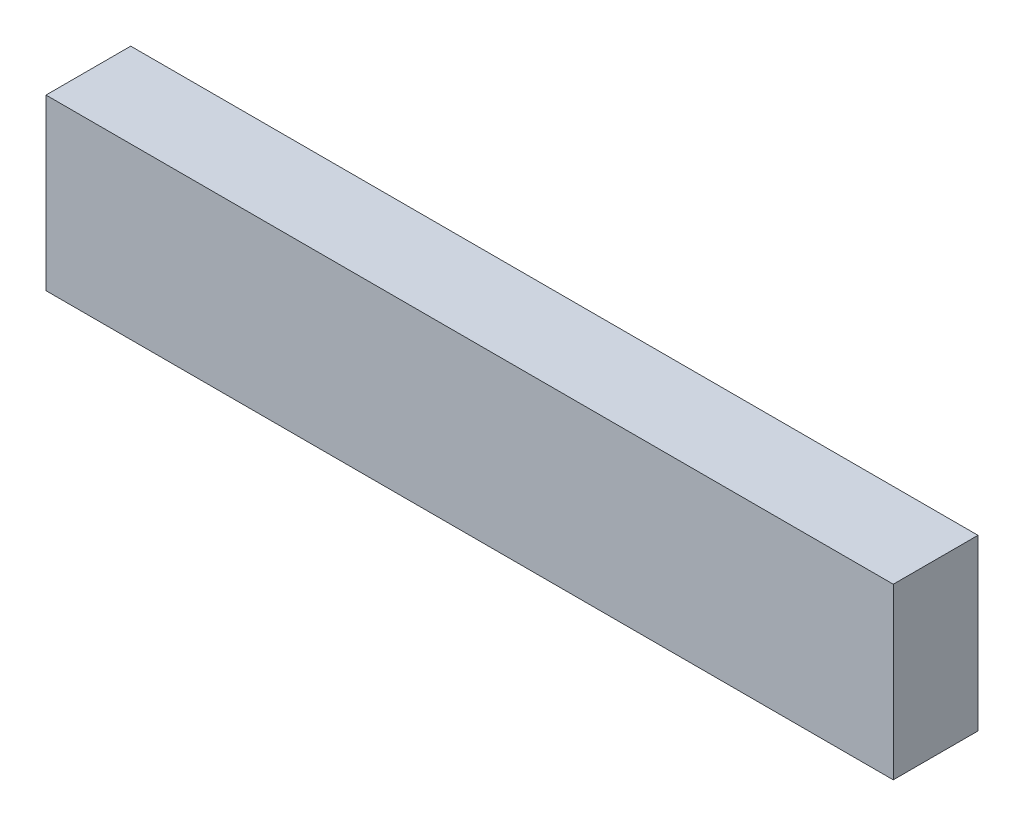
from build123d import *

# Parameters (mm, degrees)
SKETCH2_W           = 50
SKETCH2_H           = 10
BOSS_EXTRUDE1_DEPTH = 5


with BuildPart() as part:
    # Sketch2 → Boss-Extrude1 (new body)
    with BuildSketch(Plane.XY):
        with Locations((25, -5)):
            Rectangle(SKETCH2_W, SKETCH2_H)
    extrude(amount=BOSS_EXTRUDE1_DEPTH)


solid = part.part
